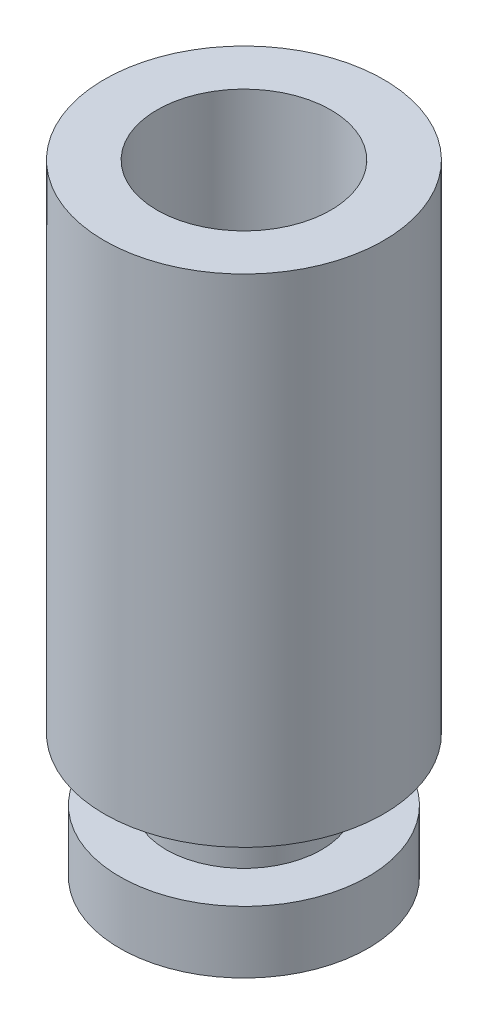
from build123d import *

# Parameters (mm, degrees)
SKETCH1_R           = 2.25
BOSS_EXTRUDE1_DEPTH = 8
SKETCH1_3_R         = 1.375
BOSS_EXTRUDE2_DEPTH = 1
SKETCH5_R           = 1.25
BOSS_EXTRUDE3_DEPTH = 1
SKETCH6_R           = 2
BOSS_EXTRUDE4_DEPTH = 1
SKETCH12_R          = 1.4
CUT_EXTRUDE1_DEPTH  = 7.5


with BuildPart() as part:
    # Sketch1 → Boss-Extrude1 (new body)
    with BuildSketch(Plane(origin=(0, 0, 0), x_dir=(1, 0, 0), z_dir=(0, 1, 0))):
        with Locations((-0.522013312, 0.511138034)):
            Circle(SKETCH1_R)
    extrude(amount=BOSS_EXTRUDE1_DEPTH)

    # Sketch1_3 → Boss-Extrude2 (add)
    with BuildSketch(Plane(origin=(0, 0, 0), x_dir=(1, 0, 0), z_dir=(0, 1, 0))):
        with Locations((-0.522013312, 0.511138034)):
            Circle(SKETCH1_3_R)
    extrude(amount=BOSS_EXTRUDE2_DEPTH)

    # Sketch5 → Boss-Extrude3 (add)
    with BuildSketch(Plane.XZ):
        with Locations((-0.522013312, -0.511138034)):
            Circle(SKETCH5_R)
    extrude(amount=BOSS_EXTRUDE3_DEPTH)

    # Sketch6 → Boss-Extrude4 (add)
    with BuildSketch(Plane.XZ.offset(1)):
        with Locations((-0.522013312, -0.511138034)):
            Circle(SKETCH6_R)
    extrude(amount=BOSS_EXTRUDE4_DEPTH)

    # Sketch12 → Cut-Extrude1 (cut)
    with BuildSketch(Plane(origin=(0, 8, 0), x_dir=(1, 0, 0), z_dir=(0, 1, 0))):
        with Locations((-0.522013312, 0.511138034)):
            Circle(SKETCH12_R)
    extrude(amount=-CUT_EXTRUDE1_DEPTH, mode=Mode.SUBTRACT)


solid = part.part
